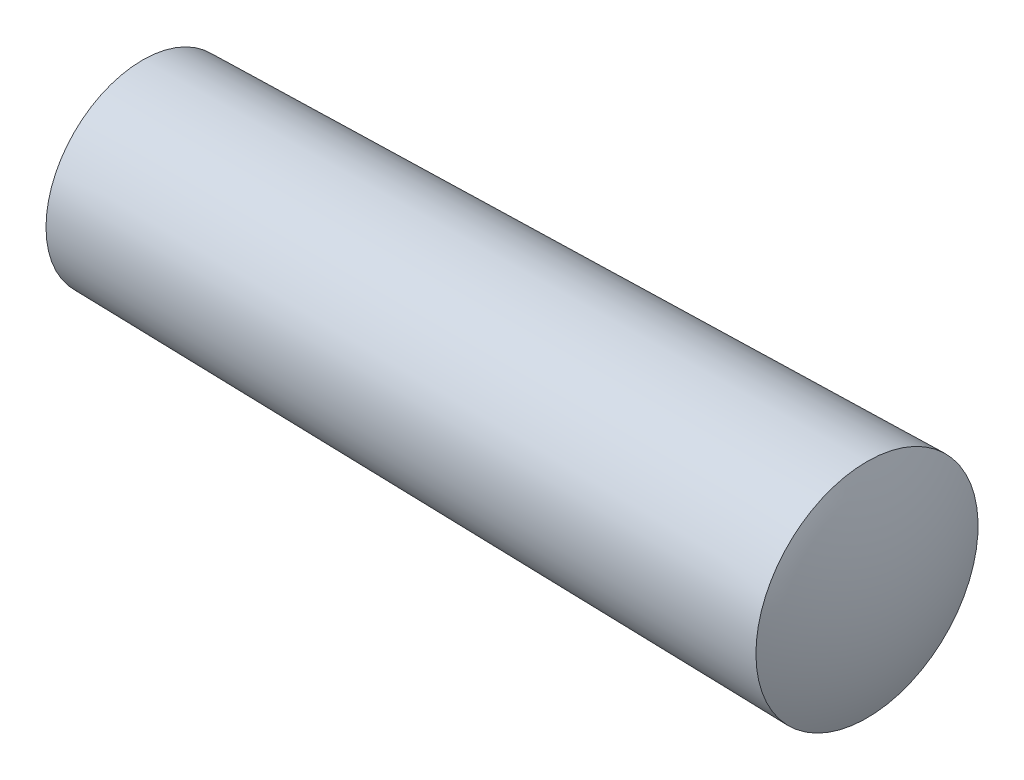
from build123d import *


with BuildPart() as part:
    # Sketch1 → Base-Revolve (revolve)
    with BuildSketch(Plane.XY):
        with BuildLine():
            Line((0, 0), (32, 0))
            ThreePointArc((32, 0), (31.747114112, 2.353720459), (31, 4.6))
            Line((31, 4.6), (1, 4))
            ThreePointArc((1, 4), (0.253788749, 2.061552813), (0, 0))
        make_face()
    revolve(axis=Axis((-4.003548939, 0, 0), (1, 0, 0)))


solid = part.part
